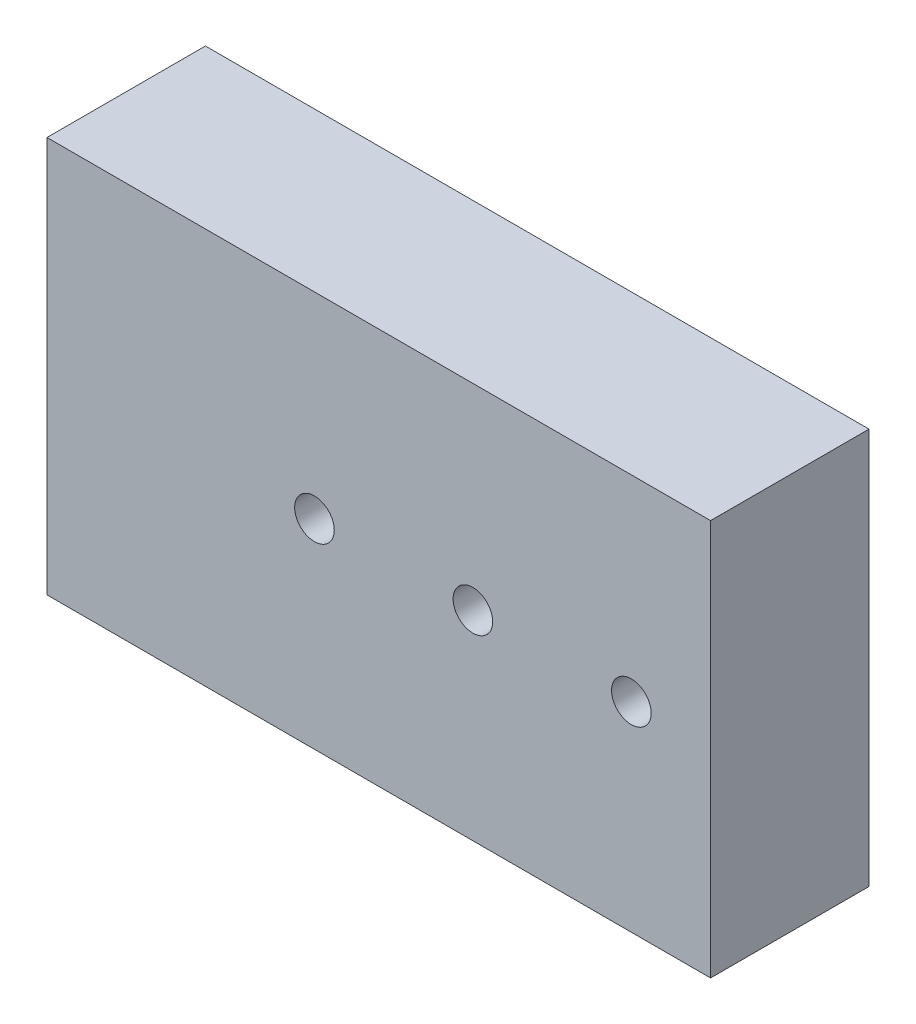
from build123d import *

# Parameters (mm, degrees)
SKETCH1_W                   = 25.4
SKETCH1_H                   = 63.5
BOSS_EXTRUDE1_DEPTH         = 106.37596
F_1_4_0_25_DIAMETER_HOLE1_D = 6.35
F_6_0MM_DOWEL_HOLE1_D       = 6.3
F_6_0MM_DOWEL_HOLE1_DEPTH   = 9.0000074
F_6_0MM_DOWEL_HOLE1_TIP     = 1.89271095


with BuildPart() as part:
    # Sketch1 → Boss-Extrude1 (new body)
    with BuildSketch(Plane(origin=(0, 0, 0), x_dir=(0, 0, -1), z_dir=(1, 0, 0))):
        with Locations((12.7, 31.75)):
            Rectangle(SKETCH1_W, SKETCH1_H)
    extrude(amount=BOSS_EXTRUDE1_DEPTH)

    # 1/4 (0.25) Diameter Hole1 (through all)
    with Locations(Plane.XY):
        with Locations((42.87596001, 32), (93.67596001, 32), (68.27596001, 32)):
            Hole(F_1_4_0_25_DIAMETER_HOLE1_D / 2)

    # Ø6.0mm Dowel Hole1
    with Locations(Plane.ZY):
        with Locations((-15.4, 7), (-15.4, 53)):
            Hole(F_6_0MM_DOWEL_HOLE1_D / 2, depth=F_6_0MM_DOWEL_HOLE1_DEPTH)
            with Locations((0, 0, -(F_6_0MM_DOWEL_HOLE1_DEPTH + F_6_0MM_DOWEL_HOLE1_TIP / 2))):  # 118° drill point
                Cone(0, F_6_0MM_DOWEL_HOLE1_D / 2, F_6_0MM_DOWEL_HOLE1_TIP, mode=Mode.SUBTRACT)


solid = part.part
